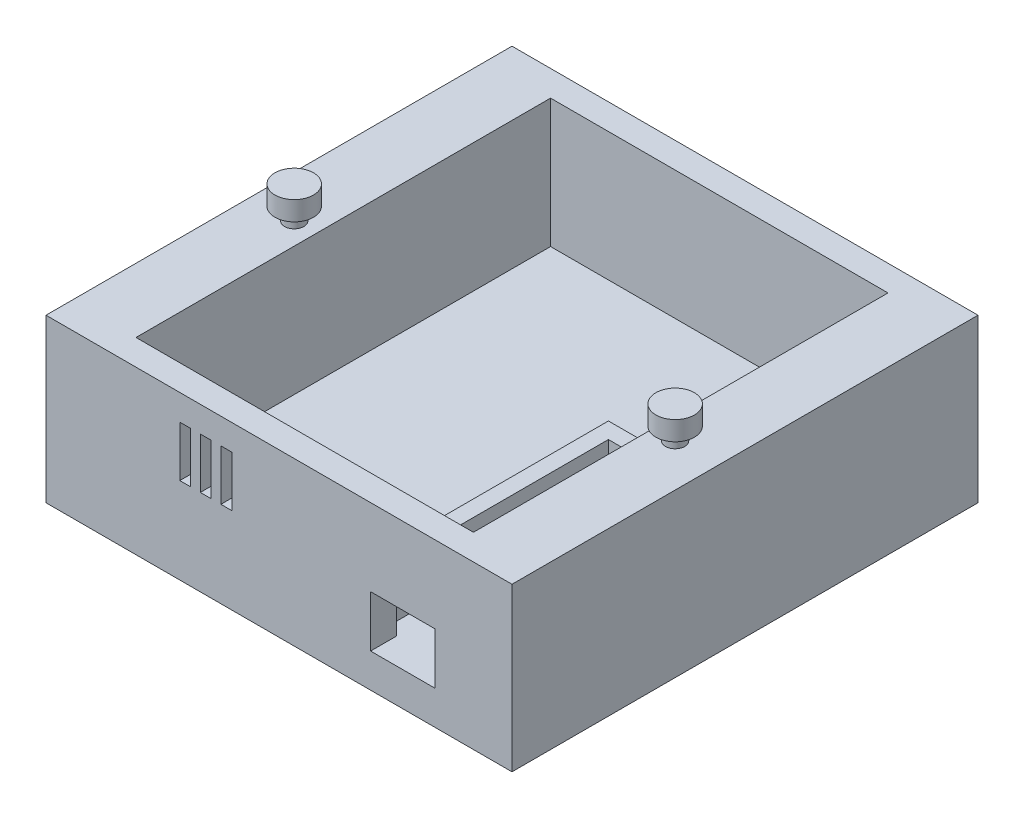
from build123d import *

# Parameters (mm, degrees)
SKETCH1_W           = 92.075
SKETCH1_H           = 92.075
BOSS_EXTRUDE1_DEPTH = 32.1
SKETCH3_W           = 66.675
SKETCH3_H           = 81.915
CUT_EXTRUDE2_DEPTH  = 25.4
SKETCH4_R           = 1.905
BOSS_EXTRUDE2_DEPTH = 2.54
SKETCH4_3_R         = 1.905
BOSS_EXTRUDE3_DEPTH = 2.54
SKETCH8_W           = 2.142857143
SKETCH8_H           = 10
CUT_EXTRUDE4_DEPTH  = 7
BOSS_EXTRUDE5_DEPTH = 10.16
SKETCH11_W          = 12.7
SKETCH11_H          = 10.16
CUT_EXTRUDE5_DEPTH  = 7.62
SKETCH15_R          = 3.81
BOSS_EXTRUDE7_DEPTH = 3.81


with BuildPart() as part:
    # Sketch1 → Boss-Extrude1 (new body)
    with BuildSketch(Plane(origin=(0, 0, 0), x_dir=(1, 0, 0), z_dir=(0, 1, 0))):
        with Locations((46.0375, 46.0375)):
            Rectangle(SKETCH1_W, SKETCH1_H)
    extrude(amount=BOSS_EXTRUDE1_DEPTH)

    # Sketch3 → Cut-Extrude2 (cut)
    with BuildSketch(Plane(origin=(0, 32.1, 0), x_dir=(1, 0, 0), z_dir=(0, 1, 0))):
        with Locations((46.0375, 46.0375)):
            Rectangle(SKETCH3_W, SKETCH3_H)
    extrude(amount=-CUT_EXTRUDE2_DEPTH, mode=Mode.SUBTRACT)

    # Sketch4 → Boss-Extrude2 (add)
    with BuildSketch(Plane(origin=(0, 32.1, 0), x_dir=(1, 0, 0), z_dir=(0, 1, 0))):
        with Locations((8.405, 40.64)):
            Circle(SKETCH4_R)
    extrude(amount=BOSS_EXTRUDE2_DEPTH)

    # Sketch4_3 → Boss-Extrude3 (add)
    with BuildSketch(Plane(origin=(0, 32.1, 0), x_dir=(1, 0, 0), z_dir=(0, 1, 0))):
        with Locations((8.405, 40.64)):
            Circle(SKETCH4_3_R)
        with Locations((83.67, 40.64)):
            Circle(SKETCH4_3_R)
    extrude(amount=BOSS_EXTRUDE3_DEPTH)

    # Sketch8 → Cut-Extrude4 (cut)
    with BuildSketch(Plane.XY):
        with Locations((27.503571429, 22.02)):
            Rectangle(SKETCH8_W, SKETCH8_H)
        with Locations((31.567571429, 22.02)):
            Rectangle(SKETCH8_W, SKETCH8_H)
        with Locations((35.631571429, 22.02)):
            Rectangle(SKETCH8_W, SKETCH8_H)
    extrude(amount=-CUT_EXTRUDE4_DEPTH, mode=Mode.SUBTRACT)

    # Sketch10 → Boss-Extrude5 (add)
    with BuildSketch(Plane(origin=(0, 6.7, 0), x_dir=(1, 0, 0), z_dir=(0, 1, 0))):
        Polygon((61.595, 49.53), (79.375, 49.53), (79.375, 52.705), (58.42, 52.705), (58.42, 5.08), (61.595, 5.08), align=None)
    extrude(amount=BOSS_EXTRUDE5_DEPTH)

    # Sketch11 → Cut-Extrude5 (cut)
    with BuildSketch(Plane.XY):
        with Locations((70.485, 11.78)):
            Rectangle(SKETCH11_W, SKETCH11_H)
    extrude(amount=-CUT_EXTRUDE5_DEPTH, mode=Mode.SUBTRACT)

    # Sketch15 → Boss-Extrude7 (add)
    with BuildSketch(Plane(origin=(0, 34.64, 0), x_dir=(1, 0, 0), z_dir=(0, 1, 0))):
        with Locations((8.405, 40.64)):
            Circle(SKETCH15_R)
        with Locations((83.67, 40.64)):
            Circle(SKETCH15_R)
    extrude(amount=BOSS_EXTRUDE7_DEPTH)


solid = part.part
